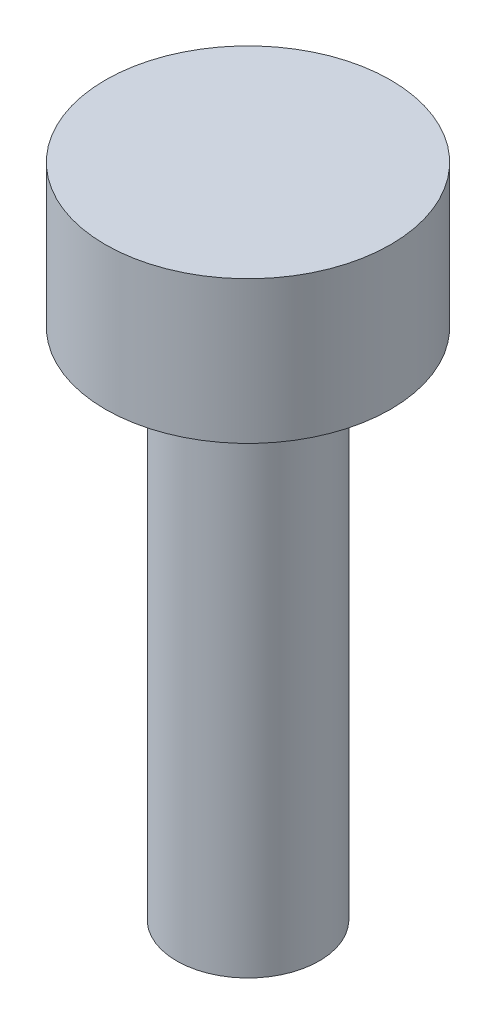
from build123d import *

# Parameters (mm, degrees)
SKETCH1_R           = 5
BOSS_EXTRUDE1_DEPTH = 36
SKETCH2_R           = 10
BOSS_EXTRUDE2_DEPTH = 10


with BuildPart() as part:
    # Sketch1 → Boss-Extrude1 (new body)
    with BuildSketch(Plane(origin=(0, 0, 0), x_dir=(1, 0, 0), z_dir=(0, 1, 0))):
        Circle(SKETCH1_R)
    extrude(amount=BOSS_EXTRUDE1_DEPTH)

    # Sketch2 → Boss-Extrude2 (add)
    with BuildSketch(Plane(origin=(0, 36, 0), x_dir=(1, 0, 0), z_dir=(0, 1, 0))):
        Circle(SKETCH2_R)
    extrude(amount=BOSS_EXTRUDE2_DEPTH)


solid = part.part
